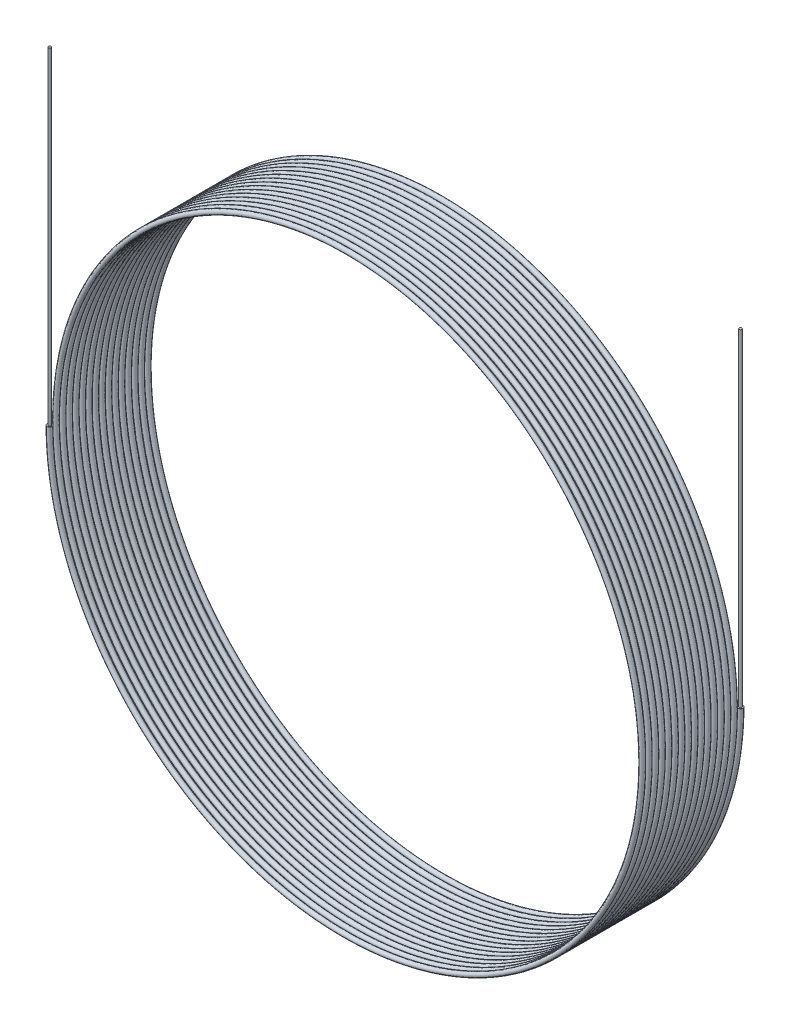
from build123d import *

# Parameters (mm, degrees)
SWEEP1_PITCH        = 2
SWEEP1_HEIGHT       = 31
SWEEP1_RADIUS       = 90
SKETCH2_R           = 0.75
SKETCH3_R           = 0.4
BOSS_EXTRUDE1_DEPTH = 100


with BuildPart() as part:
    # Sweep1: sweep along a helix
    with BuildLine() as sweep1_path:
        Helix(SWEEP1_PITCH, SWEEP1_HEIGHT, SWEEP1_RADIUS, center=(0, 0, 0), direction=(0, 0, 1), lefthand=True)
    # Sketch2 → Sweep1 (sweep)
    with BuildSketch(Plane(origin=(0, 0, 0), x_dir=(1, 0, 0), z_dir=(0, 1, 0))):
        with Locations((90, 0)):
            Circle(SKETCH2_R)
    sweep(path=sweep1_path.line, is_frenet=True)

    # Sketch3 → Boss-Extrude1 (add)
    with BuildSketch(Plane(origin=(0, 0, 0), x_dir=(1, 0, 0), z_dir=(0, 1, 0))):
        with Locations((90, 0)):
            Circle(SKETCH3_R)
        with Locations((-89.948746174, -30.989269387)):
            Circle(SKETCH3_R)
    extrude(amount=BOSS_EXTRUDE1_DEPTH)


solid = part.part
